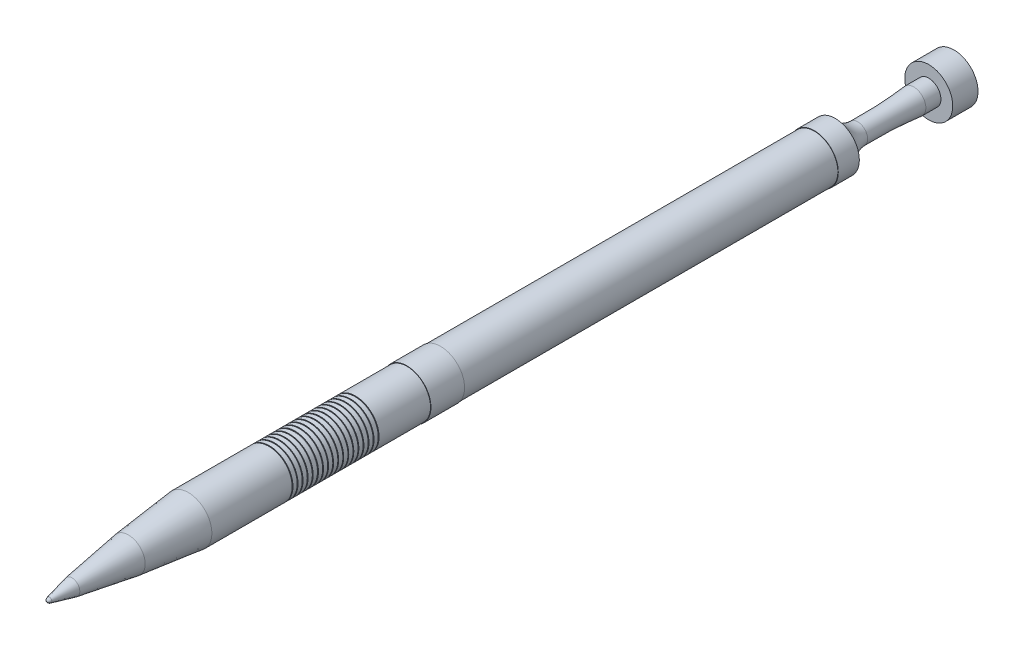
from build123d import *


with BuildPart() as part:
    # Sketch2 → Revolve3 (revolve)
    with BuildSketch(Plane(origin=(0, 0, 0), x_dir=(0, 0, -1), z_dir=(1, 0, 0))):
        with BuildLine():
            Line((30, 9.321303696), (97, 20.000000001))
            Line((97, 20.000000001), (168.233431313, 28.000000001))
            Line((168.233431313, 28.000000001), (263.567816139, 28.000000001))
            Line((263.567816139, 28.000000001), (263.567816139, 27.000000001))
            Line((263.567816139, 27.000000001), (264.567816139, 27.000000001))
            Line((264.567816139, 27.000000001), (264.567816139, 28.000000001))
            Line((264.567816139, 28.000000001), (269.567816139, 28.000000001))
            Line((269.567816139, 28.000000001), (269.567816139, 27.000000001))
            Line((269.567816139, 27.000000001), (270.567816139, 27.000000001))
            Line((270.567816139, 27.000000001), (270.567816139, 28.000000001))
            Line((270.567816139, 28.000000001), (275.567816139, 28.000000001))
            Line((275.567816139, 28.000000001), (275.567816139, 27.000000001))
            Line((275.567816139, 27.000000001), (276.567816139, 27.000000001))
            Line((276.567816139, 27.000000001), (276.567816139, 28.000000001))
            Line((276.567816139, 28.000000001), (281.567816139, 28.000000001))
            Line((281.567816139, 28.000000001), (281.567816139, 27.000000001))
            Line((281.567816139, 27.000000001), (282.567816139, 27.000000001))
            Line((282.567816139, 27.000000001), (282.567816139, 28.000000001))
            Line((282.567816139, 28.000000001), (287.567816139, 28.000000001))
            Line((287.567816139, 28.000000001), (287.567816139, 27.000000001))
            Line((287.567816139, 27.000000001), (288.567816139, 27.000000001))
            Line((288.567816139, 27.000000001), (288.567816139, 28.000000001))
            Line((288.567816139, 28.000000001), (293.567816139, 28.000000001))
            Line((293.567816139, 28.000000001), (293.567816139, 27.000000001))
            Line((293.567816139, 27.000000001), (294.879853329, 27.000000001))
            Line((294.879853329, 27.000000001), (294.879853329, 28.000000001))
            Line((294.879853329, 28.000000001), (299.879853329, 28.000000001))
            Line((299.879853329, 28.000000001), (299.879853329, 27.000000001))
            Line((299.879853329, 27.000000001), (300.879853329, 27.000000001))
            Line((300.879853329, 27.000000001), (300.879853329, 28.000000001))
            Line((300.879853329, 28.000000001), (305.879853329, 28.000000001))
            Line((305.879853329, 28.000000001), (305.879853329, 27.000000001))
            Line((305.879853329, 27.000000001), (306.879853329, 27.000000001))
            Line((306.879853329, 27.000000001), (306.879853329, 28.000000001))
            Line((306.879853329, 28.000000001), (311.879853329, 28.000000001))
            Line((311.879853329, 28.000000001), (311.879853329, 27.000000001))
            Line((311.879853329, 27.000000001), (312.879853329, 27.000000001))
            Line((312.879853329, 27.000000001), (312.879853329, 28.000000001))
            Line((312.879853329, 28.000000001), (317.879853329, 28.000000001))
            Line((317.879853329, 28.000000001), (317.879853329, 27.000000001))
            Line((317.879853329, 27.000000001), (318.879853329, 27.000000001))
            Line((318.879853329, 27.000000001), (318.879853329, 28.000000001))
            Line((318.879853329, 28.000000001), (323.879853329, 28.000000001))
            Line((323.879853329, 28.000000001), (323.879853329, 27.000000001))
            Line((323.879853329, 27.000000001), (324.879853329, 27.000000001))
            Line((324.879853329, 27.000000001), (324.879853329, 28.000000001))
            Line((324.879853329, 28.000000001), (329.879853329, 28.000000001))
            Line((329.879853329, 28.000000001), (329.879853329, 27.000000001))
            Line((329.879853329, 27.000000001), (330.879853329, 27.000000001))
            Line((330.879853329, 27.000000001), (330.879853329, 28.000000001))
            Line((330.879853329, 28.000000001), (335.879853329, 28.000000001))
            Line((335.879853329, 28.000000001), (335.879853329, 27.000000001))
            Line((335.879853329, 27.000000001), (336.879853329, 27.000000001))
            Line((336.879853329, 27.000000001), (336.879853329, 28.000000001))
            Line((336.879853329, 28.000000001), (341.879853329, 28.000000001))
            Line((341.879853329, 28.000000001), (341.879853329, 27.000000001))
            Line((341.879853329, 27.000000001), (342.879853329, 27.000000001))
            Line((342.879853329, 27.000000001), (342.879853329, 28.000000001))
            Line((342.879853329, 28.000000001), (347.879853329, 28.000000001))
            Line((347.879853329, 28.000000001), (347.879853329, 27.000000001))
            Line((347.879853329, 27.000000001), (348.879853329, 27.000000001))
            Line((348.879853329, 27.000000001), (348.879853329, 28.000000001))
            Line((348.879853329, 28.000000001), (353.879853329, 28.000000001))
            Line((353.879853329, 28.000000001), (353.879853329, 27.000000001))
            Line((353.879853329, 27.000000001), (354.879853329, 27.000000001))
            Line((354.879853329, 27.000000001), (354.879853329, 28.000000001))
            Line((354.879853329, 28.000000001), (359.879853329, 28.000000001))
            Line((359.879853329, 28.000000001), (359.879853329, 27.000000001))
            Line((359.879853329, 27.000000001), (360.879853329, 27.000000001))
            Line((360.879853329, 27.000000001), (360.879853329, 28.000000001))
            Line((360.879853329, 28.000000001), (365.879853329, 28.000000001))
            Line((365.879853329, 28.000000001), (365.879853329, 27.000000001))
            Line((365.879853329, 27.000000001), (366.879853329, 27.000000001))
            Line((366.879853329, 27.000000001), (366.879853329, 28.000000001))
            Line((366.879853329, 28.000000001), (372.567816139, 28.000000001))
            Line((372.567816139, 28.000000001), (428, 28.000000001))
            Line((428, 28.000000001), (428, 28.500000001))
            Line((428, 28.500000001), (468, 28.500000001))
            Line((468, 28.500000001), (468, 28))
            Line((468, 28), (912, 28))
            Line((912, 28), (912, 28.5))
            Line((912, 28.5), (937, 28.5))
            ThreePointArc((937, 28.5), (947.962888138, 16.474442907), (963.553914155, 11.814094484))
            ThreePointArc((963.553914155, 11.814094484), (996.859460212, 12.144463281), (1030.086140878, 14.458817111))
            Line((1030.086140878, 14.458817111), (1048, 14.458817111))
            Line((1048, 14.458817111), (1048, 28.5))
            Line((1048, 28.5), (1078, 28.5))
            Line((1078, 28.5), (1078, 1e-09))
            Line((1078, 1e-09), (0, 1e-09))
            ThreePointArc((0, 1e-09), (1.123574067, 1.978970101), (3.189727135, 2.93277975))
            Line((3.189727135, 2.93277975), (30, 9.321303696))
        make_face()
    revolve(axis=Axis((0, 1e-09, 0), (0, 0, -1)))


solid = part.part
